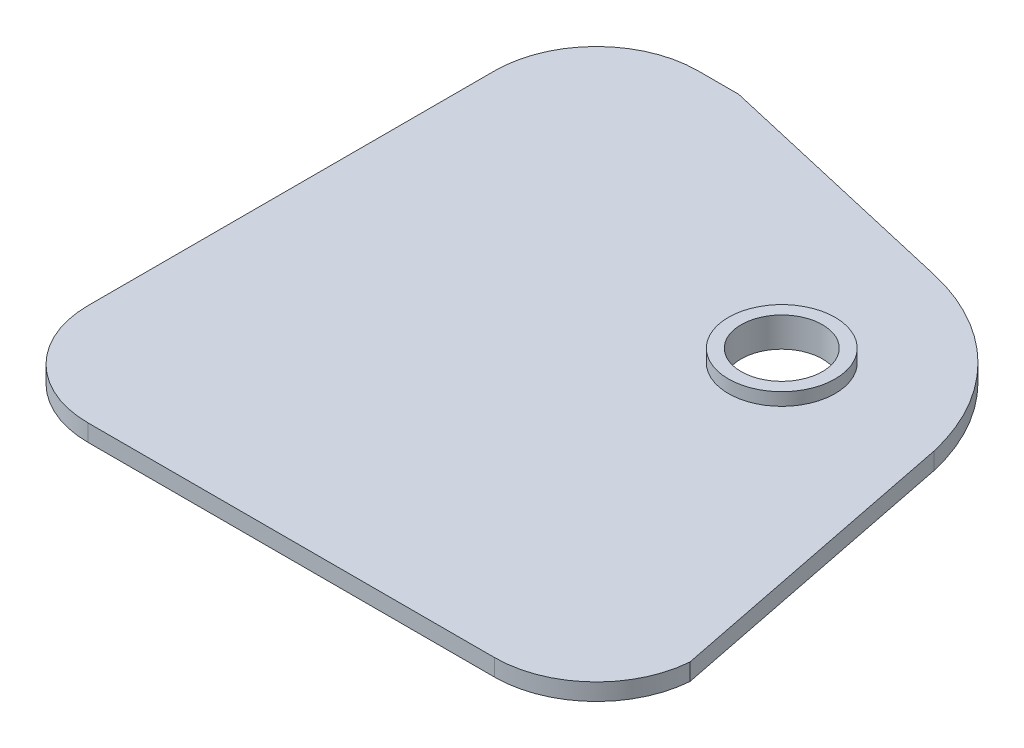
from build123d import *

# Parameters (mm, degrees)
SKETCH1_R           = 5.08
BOSS_EXTRUDE1_DEPTH = 2.116666667
SKETCH2_R           = 6.6675
SKETCH2_R_2         = 5.08
BOSS_EXTRUDE2_DEPTH = 1.5875


with BuildPart() as part:
    # Sketch1 → Boss-Extrude1 (new body)
    with BuildSketch(Plane(origin=(0, 0, 0), x_dir=(1, 0, 0), z_dir=(0, 1, 0))):
        with BuildLine():
            Line((-25.4, 50.8), (-20.32, 50.8))
            Line((-20.32, 50.8), (11.43, 43.486136085))
            ThreePointArc((11.43, 43.486136085), (23.688747156, 36.694883241), (30.48, 24.436136085))
            Line((30.48, 24.436136085), (38.06337105, -13.663863915))
            ThreePointArc((38.06337105, -13.663863915), (34.032755304, -22.014801976), (25.4, -25.4))
            Line((25.4, -25.4), (-25.4, -25.4))
            ThreePointArc((-25.4, -25.4), (-34.380256121, -21.680256121), (-38.1, -12.7))
            Line((-38.1, -12.7), (-38.1, 38.1))
            ThreePointArc((-38.1, 38.1), (-34.380256121, 47.080256121), (-25.4, 50.8))
        make_face()
        with Locations((11.43, 24.436136085)):
            Circle(SKETCH1_R, mode=Mode.SUBTRACT)
    extrude(amount=BOSS_EXTRUDE1_DEPTH)

    # Sketch2 → Boss-Extrude2 (add)
    with BuildSketch(Plane(origin=(0, 2.116666667, 0), x_dir=(1, 0, 0), z_dir=(0, 1, 0))):
        with Locations((11.43, 24.436136085)):
            Circle(SKETCH2_R)
        with Locations((11.43, 24.436136085)):
            Circle(SKETCH2_R_2, mode=Mode.SUBTRACT)
    extrude(amount=BOSS_EXTRUDE2_DEPTH)


solid = part.part
